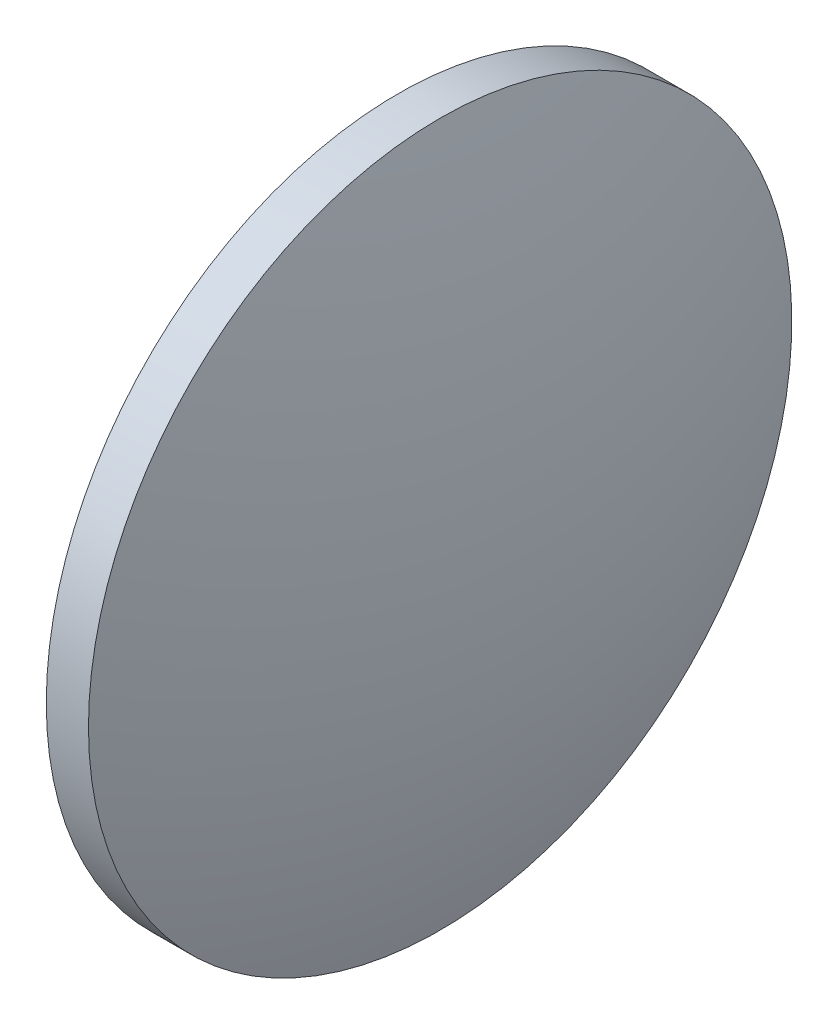
from build123d import *


with BuildPart() as part:
    # 草图1 → 旋转1 (revolve)
    with BuildSketch(Plane.XY):
        with BuildLine():
            Line((415.811375189, 102.301186731), (415.811375189, 127.301186731))
            Line((415.811375189, 127.301186731), (418.811375189, 127.301186731))
            ThreePointArc((418.811375189, 127.301186731), (421.708147551, 114.950069093), (422.681375189, 102.301186731))
            Line((422.681375189, 102.301186731), (415.811375189, 102.301186731))
        make_face()
    revolve(axis=Axis((406.389135752, 102.301186731, 0), (1, 0, 0)))


solid = part.part
